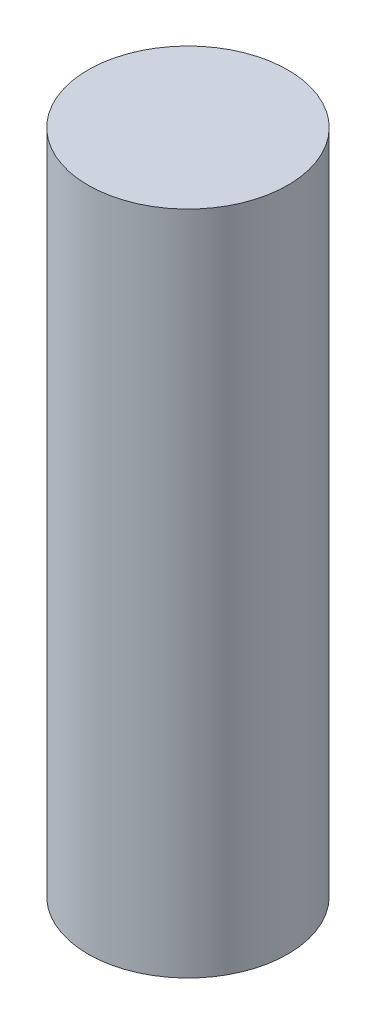
from build123d import *

# Parameters (mm, degrees)
SKETCH1_R               = 6
BOSS_EXTRUDE1_DEPTH     = 40
CUT_EXTRUDE3_DEPTH      = 1
CUT_EXTRUDE3_DEPTH_BACK = 30


with BuildPart() as part:
    # Sketch1 → Boss-Extrude1 (new body)
    with BuildSketch(Plane(origin=(0, 0, 0), x_dir=(1, 0, 0), z_dir=(0, 1, 0))):
        Circle(SKETCH1_R)
    extrude(amount=BOSS_EXTRUDE1_DEPTH)

    # Sketch2 → Cut-Extrude3 (cut, two sides)
    with BuildSketch(Plane.XZ) as cut_extrude3_sk:
        with BuildLine():
            Line((1.645448267, 2.09), (-1.645448267, 2.09))
            ThreePointArc((-1.645448267, 2.09), (-1.161616892, -2.392957625), (2.66, 0))
            ThreePointArc((2.66, 0), (2.392957625, 1.161616892), (1.645448267, 2.09))
        make_face()
    extrude(amount=CUT_EXTRUDE3_DEPTH, mode=Mode.SUBTRACT)
    extrude(cut_extrude3_sk.sketch, amount=-CUT_EXTRUDE3_DEPTH_BACK, mode=Mode.SUBTRACT)


solid = part.part
